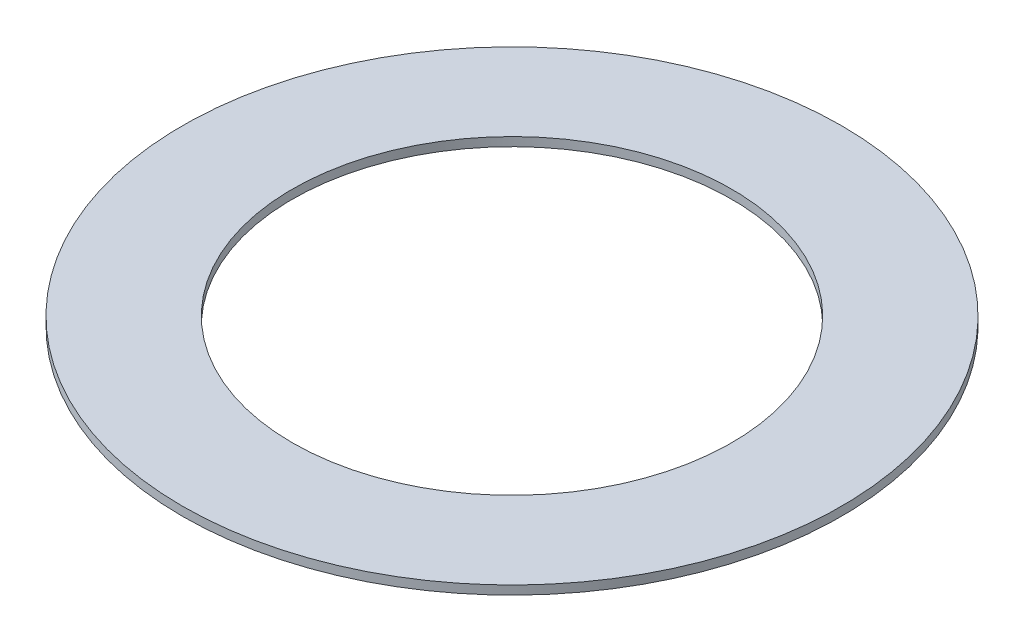
from build123d import *

# Parameters (mm, degrees)
SKETCH1_W = 1.5875
SKETCH1_H = 0.127


with BuildPart() as part:
    # Sketch1 → Revolve1 (revolve)
    with BuildSketch(Plane.XY):
        with Locations((-3.96875, 0.0635)):
            Rectangle(SKETCH1_W, SKETCH1_H)
    revolve(axis=Axis((0, 52.5, 0), (0, -1, 0)))


solid = part.part
